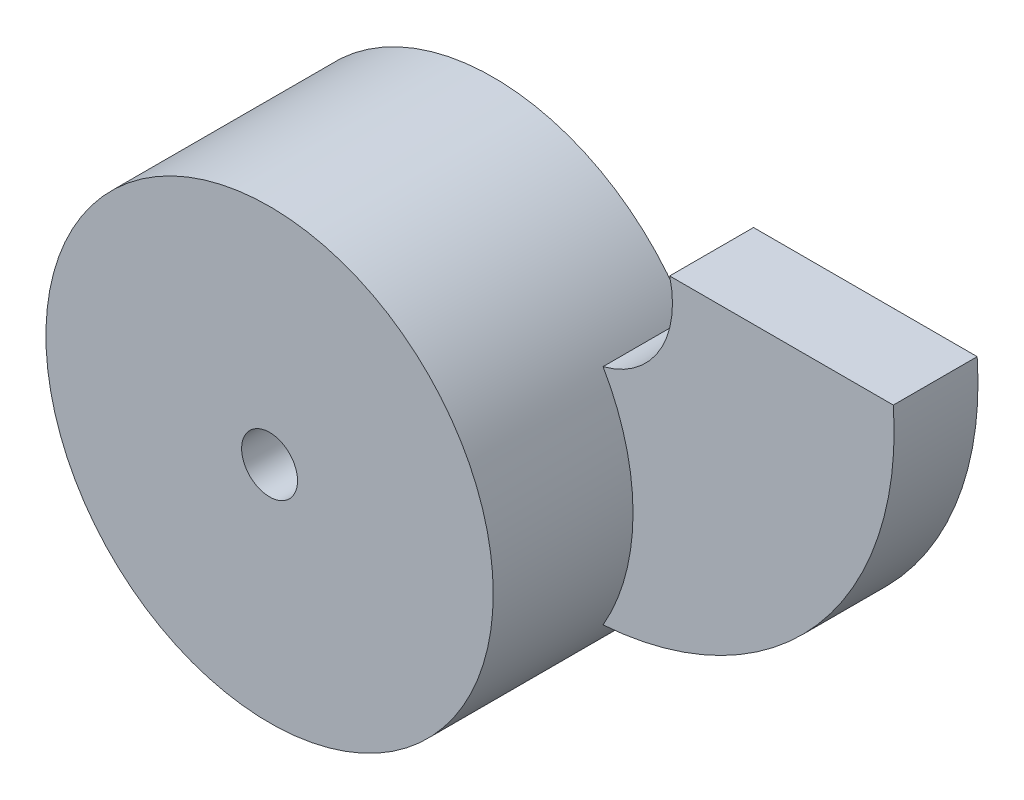
from build123d import *

# Parameters (mm, degrees)
SKETCH1_R           = 5
BOSS_EXTRUDE1_DEPTH = 15
SKETCH5_R           = 40
SKETCH5_R_2         = 5
BOSS_EXTRUDE2_DEPTH = 25


with BuildPart() as part:
    # Sketch1 → Boss-Extrude1 (new body)
    with BuildSketch(Plane.XY):
        with BuildLine():
            Line((0, 0), (40, 0))
            ThreePointArc((40, 0), (26.472356234, -40.750519772), (-11.908101275, -60))
            ThreePointArc((-11.908101275, -60), (-86.549117426, -40), (-11.908101275, -20))
            ThreePointArc((-11.908101275, -20), (-1.811915014, -12.466248525), (0, 0))
        make_face()
        with Locations((-46.549117426, -40)):
            Circle(SKETCH1_R, mode=Mode.SUBTRACT)
    extrude(amount=BOSS_EXTRUDE1_DEPTH)

    # Sketch5 → Boss-Extrude2 (add)
    with BuildSketch(Plane.XY.offset(15)):
        with Locations((-46.549117426, -40)):
            Circle(SKETCH5_R)
        with Locations((-46.549117426, -40)):
            Circle(SKETCH5_R_2, mode=Mode.SUBTRACT)
    extrude(amount=BOSS_EXTRUDE2_DEPTH)


solid = part.part
